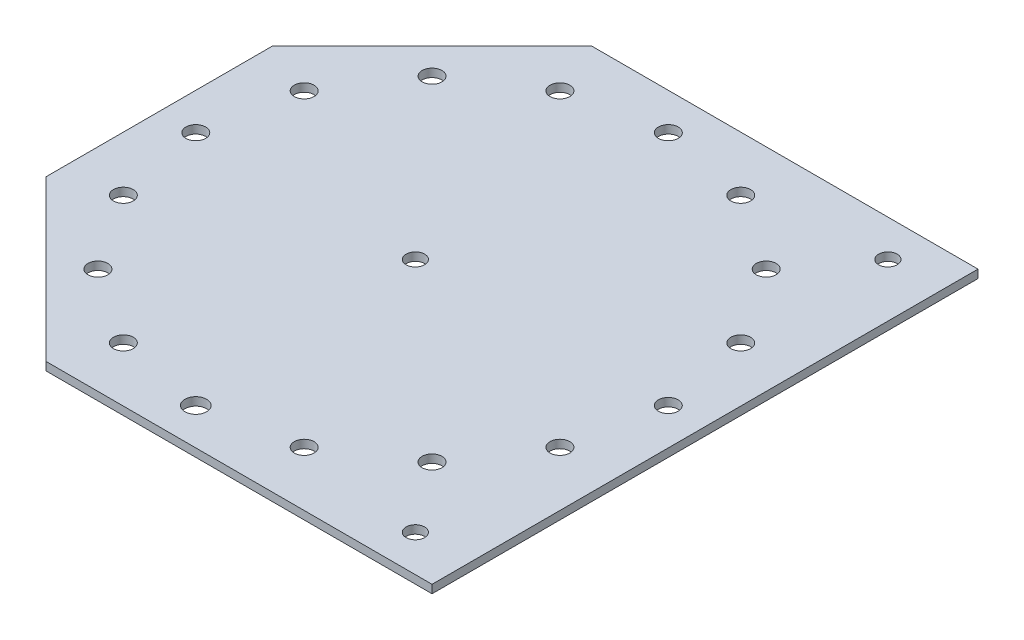
from build123d import *

# Parameters (mm, degrees)
SKETCH1_R           = 3.374999999
SKETCH1_R_2         = 3.375000001
SKETCH1_R_3         = 3.375000002
SKETCH1_R_4         = 3.606945722
SKETCH1_R_5         = 3.951125178
BOSS_EXTRUDE1_DEPTH = 3


with BuildPart() as part:
    # Sketch1 → Boss-Extrude1 (new body)
    with BuildSketch(Plane(origin=(0, 0, 0), x_dir=(1, 0, 0), z_dir=(0, 1, 0))):
        Polygon((-41.199524293, -99.465227688), (-99.465227688, -41.199524293), (-99.465250609, 41.199501372), (-41.199524293, 99.465227688), (99.465250609, 99.465227688), (99.465250609, -99.465227688), align=None)
        with Locations((80.004750061, 86.09025128)):
            Circle(SKETCH1_R, mode=Mode.SUBTRACT)
        with Locations((-6.085500548, 6.7e-07)):
            Circle(SKETCH1_R_2, mode=Mode.SUBTRACT)
        with Locations((80.004750061, -86.090249939)):
            Circle(SKETCH1_R_3, mode=Mode.SUBTRACT)
        with Locations((-79.537020487, -32.945312596)):
            Circle(SKETCH1_R_4, mode=Mode.SUBTRACT)
        with Locations((-60.875, -60.875)):
            Circle(SKETCH1_R_4, mode=Mode.SUBTRACT)
        with Locations((-32.945312596, -79.537020487)):
            Circle(SKETCH1_R_4, mode=Mode.SUBTRACT)
        with Locations((32.945312596, -79.537020487)):
            Circle(SKETCH1_R_4, mode=Mode.SUBTRACT)
        with Locations((60.875, -60.875)):
            Circle(SKETCH1_R_4, mode=Mode.SUBTRACT)
        with Locations((79.537020487, -32.945312596)):
            Circle(SKETCH1_R_4, mode=Mode.SUBTRACT)
        with Locations((86.090250609, 0)):
            Circle(SKETCH1_R_4, mode=Mode.SUBTRACT)
        with Locations((79.537020487, 32.945312596)):
            Circle(SKETCH1_R_4, mode=Mode.SUBTRACT)
        with Locations((60.875, 60.875)):
            Circle(SKETCH1_R_4, mode=Mode.SUBTRACT)
        with Locations((32.945312596, 79.537020487)):
            Circle(SKETCH1_R_4, mode=Mode.SUBTRACT)
        with Locations((0, 86.090250609)):
            Circle(SKETCH1_R_4, mode=Mode.SUBTRACT)
        with Locations((-32.945312596, 79.537020487)):
            Circle(SKETCH1_R_4, mode=Mode.SUBTRACT)
        with Locations((-60.875, 60.875)):
            Circle(SKETCH1_R_4, mode=Mode.SUBTRACT)
        with Locations((-79.537020487, 32.945312596)):
            Circle(SKETCH1_R_4, mode=Mode.SUBTRACT)
        with Locations((-86.090250609, 0)):
            Circle(SKETCH1_R_4, mode=Mode.SUBTRACT)
        with Locations((0, -86.090250609)):
            Circle(SKETCH1_R_5, mode=Mode.SUBTRACT)
    extrude(amount=BOSS_EXTRUDE1_DEPTH)


solid = part.part
